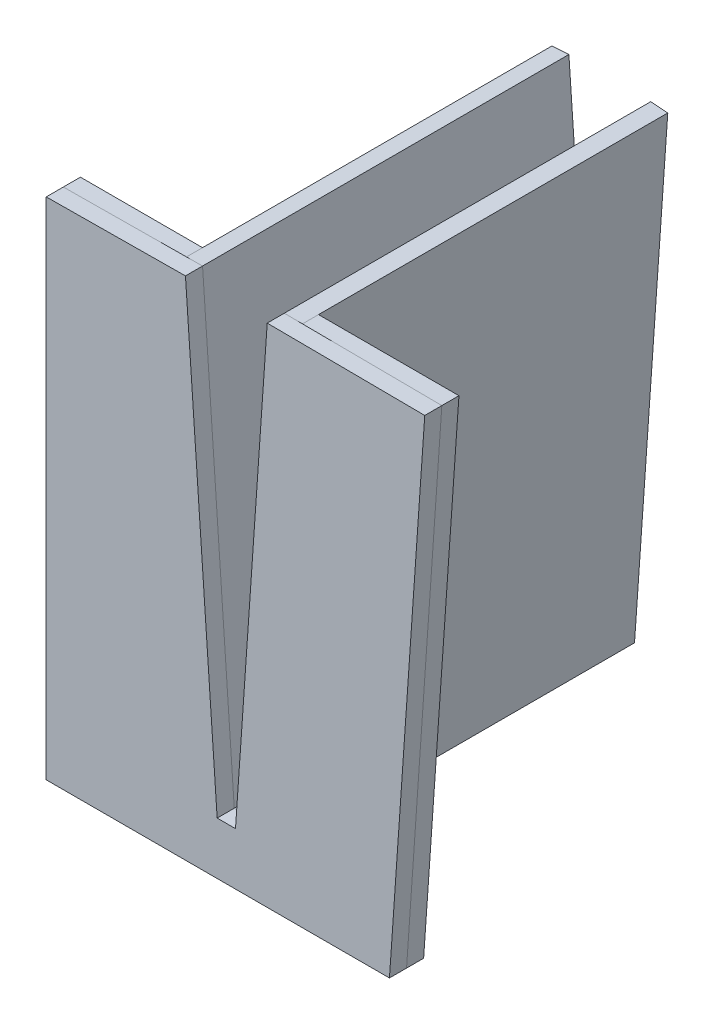
from build123d import *

# Parameters (mm, degrees)
BOSS_EXTRUDE1_DEPTH   = 30
BOSS_EXTRUDE1_2_DEPTH = 30
BOSS_EXTRUDE2_DEPTH   = 2.8
BOSS_EXTRUDE3_DEPTH   = 2.8


with BuildPart() as part:
    # Sketch1 → Boss-Extrude1 (new body, symmetric)
    with BuildSketch(Plane.XY):
        Polygon((-1.25, 0), (-6.695608717, 77.875832821), (-9.495608717, 77.680037747), (-4.05, -0.195795073), align=None)
    extrude(amount=BOSS_EXTRUDE1_DEPTH, both=True)


with BuildPart() as body_2:
    # Sketch1 → Boss-Extrude1 2 (new body, symmetric)
    with BuildSketch(Plane.XY):
        Polygon((1.25, 0), (6.695608717, 77.875832821), (9.495608717, 77.680037747), (4.05, -0.195795073), align=None)
    extrude(amount=BOSS_EXTRUDE1_2_DEPTH, both=True)


with BuildPart() as body_3:
    # Sketch2 → Boss-Extrude2 (new body)
    with BuildSketch(Plane.XY.offset(30)):
        Polygon((-1.5, 3.575166564), (1.5, 3.575166564), (1.25, 0), (4.05, -0.195795073), (9.495608717, 77.680037747), (32.495608717, 77.680037747), (26.714057266, -5), (-29.495608717, -5), (-29.495608717, 77.680037747), (-9.495608717, 77.680037747), (-4.05, -0.195795073), (-1.25, 0), align=None)
    extrude(amount=-BOSS_EXTRUDE2_DEPTH)


with BuildPart() as body_4:
    # Sketch3 → Boss-Extrude3 (new body)
    with BuildSketch(Plane.XY.offset(30)):
        Polygon((-6.695608717, 77.875832821), (-29.495608717, 77.680037747), (-29.495608717, -5), (26.714057266, -5), (32.495608717, 77.680037747), (6.695608717, 77.875832821), (1.5, 3.575166564), (-1.5, 3.575166564), align=None)
    extrude(amount=BOSS_EXTRUDE3_DEPTH)


solid = Compound([part.part, body_2.part, body_3.part, body_4.part])
